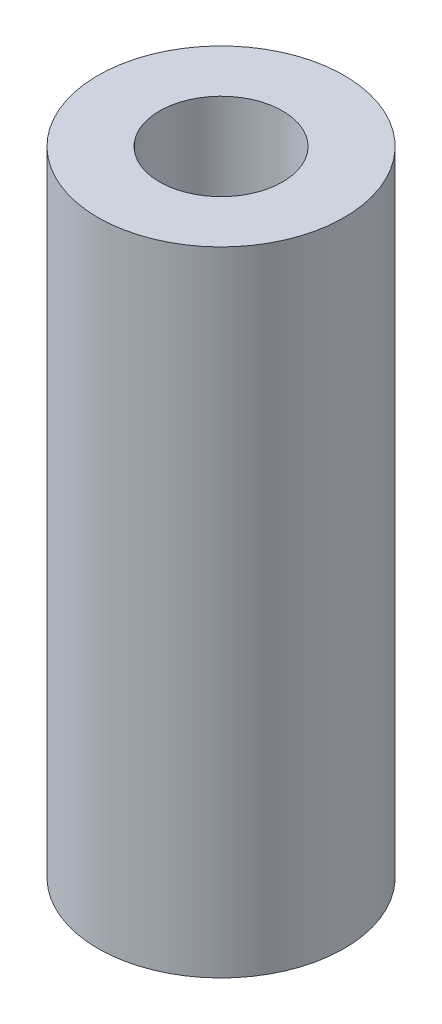
from build123d import *

# Parameters (mm, degrees)
SKETCH1_R           = 3.5
SKETCH1_R_2         = 1.75
BOSS_EXTRUDE1_DEPTH = 18


with BuildPart() as part:
    # Sketch1 → Boss-Extrude1 (new body)
    with BuildSketch(Plane(origin=(0, 0, 0), x_dir=(1, 0, 0), z_dir=(0, 1, 0))):
        Circle(SKETCH1_R)
        Circle(SKETCH1_R_2, mode=Mode.SUBTRACT)
    extrude(amount=BOSS_EXTRUDE1_DEPTH)


solid = part.part
